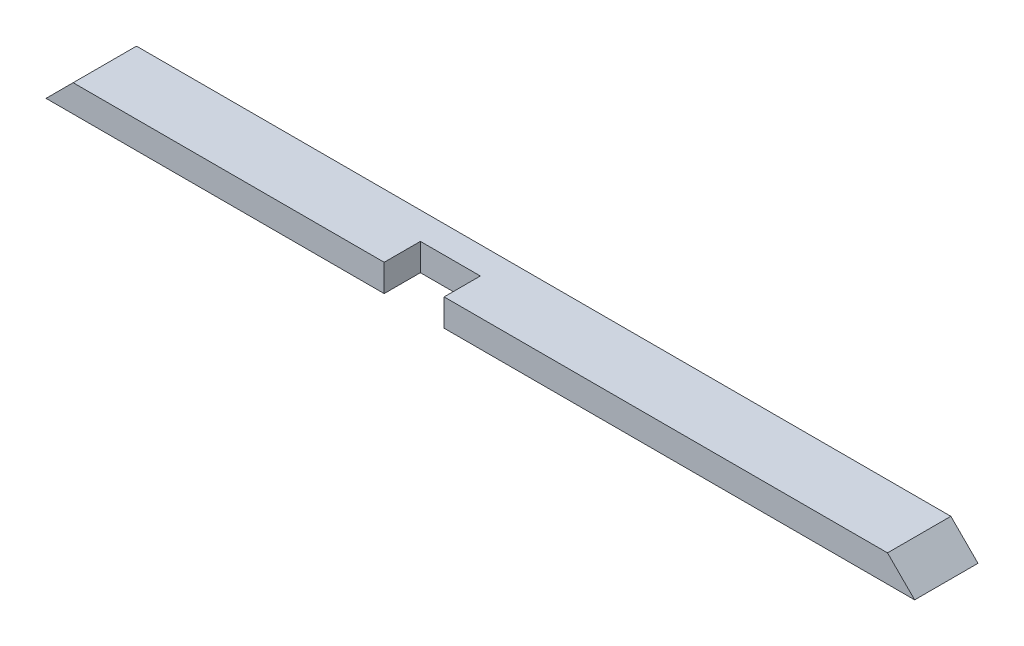
from build123d import *

# Parameters (mm, degrees)
SKETCH1_W           = 1219.2
SKETCH1_H           = 88.9
BOSS_EXTRUDE1_DEPTH = 38.1
CUT_EXTRUDE1_DEPTH  = 89.9
SKETCH3_W           = 84.1375
SKETCH3_H           = 50.8
CUT_EXTRUDE2_DEPTH  = 39.1


with BuildPart() as part:
    # Sketch1 → Boss-Extrude1 (new body)
    with BuildSketch(Plane(origin=(0, 0, 0), x_dir=(1, 0, 0), z_dir=(0, 1, 0))):
        with Locations((609.6, 44.45)):
            Rectangle(SKETCH1_W, SKETCH1_H)
    extrude(amount=BOSS_EXTRUDE1_DEPTH)

    # Sketch2 → Cut-Extrude1 (cut, through all)
    with BuildSketch(Plane.XY):
        Polygon((0, 0), (38.1, 38.1), (0, 38.1), align=None)
        Polygon((1219.2, 0), (1219.2, 38.1), (1181.1, 38.1), align=None)
    extrude(amount=-CUT_EXTRUDE1_DEPTH, mode=Mode.SUBTRACT)

    # Sketch3 → Cut-Extrude2 (cut, through all)
    with BuildSketch(Plane.XZ):
        with Locations((516.73125, -25.4)):
            Rectangle(SKETCH3_W, SKETCH3_H)
    extrude(amount=-CUT_EXTRUDE2_DEPTH, mode=Mode.SUBTRACT)


solid = part.part
